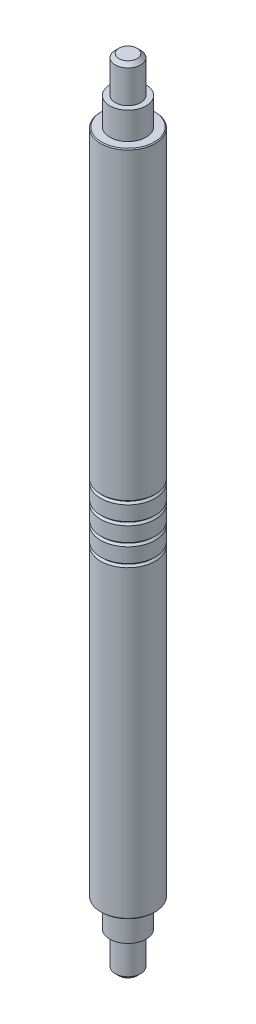
from build123d import *

# Parameters (mm, degrees)
SKETCH1_R           = 1.5
BOSS_EXTRUDE1_DEPTH = 43.75
SKETCH2_OUTSIDE_W   = 13.792
SKETCH2_OUTSIDE_H   = 13.792
SKETCH2_OUTSIDE_R   = 1
CUT_EXTRUDE1_DEPTH  = 3.5
SKETCH3_OUTSIDE_W   = 13.792
SKETCH3_OUTSIDE_H   = 13.792
SKETCH3_OUTSIDE_R   = 0.7
CUT_EXTRUDE2_DEPTH  = 2
SKETCH4_OUTSIDE_W   = 13.792
SKETCH4_OUTSIDE_H   = 13.792
SKETCH4_OUTSIDE_R   = 1
CUT_EXTRUDE5_DEPTH  = 3.5
SKETCH5_OUTSIDE_W   = 13.792
SKETCH5_OUTSIDE_H   = 13.792
SKETCH5_OUTSIDE_R   = 0.7
CUT_EXTRUDE6_DEPTH  = 2
LPATTERN1_COUNT     = 4
LPATTERN1_PITCH     = 1
CHAMFER3_SIZE       = 0.2
CHAMFER4_SIZE       = 0.05


with BuildPart() as part:
    # Sketch1 → Boss-Extrude1 (new body)
    with BuildSketch(Plane(origin=(0, 0, 0), x_dir=(1, 0, 0), z_dir=(0, 1, 0))):
        Circle(SKETCH1_R)
    extrude(amount=BOSS_EXTRUDE1_DEPTH)

    # Sketch2 outside → Cut-Extrude1 (cut)
    with BuildSketch(Plane(origin=(0, 43.75, 0), x_dir=(1, 0, 0), z_dir=(0, 1, 0))):
        Rectangle(SKETCH2_OUTSIDE_W, SKETCH2_OUTSIDE_H)
        Circle(SKETCH2_OUTSIDE_R, mode=Mode.SUBTRACT)
    extrude(amount=-CUT_EXTRUDE1_DEPTH, mode=Mode.SUBTRACT)

    # Sketch3 outside → Cut-Extrude2 (cut)
    with BuildSketch(Plane(origin=(0, 43.75, 0), x_dir=(1, 0, 0), z_dir=(0, 1, 0))):
        Rectangle(SKETCH3_OUTSIDE_W, SKETCH3_OUTSIDE_H)
        Circle(SKETCH3_OUTSIDE_R, mode=Mode.SUBTRACT)
    extrude(amount=-CUT_EXTRUDE2_DEPTH, mode=Mode.SUBTRACT)

    # Sketch4 outside → Cut-Extrude5 (cut)
    with BuildSketch(Plane.XZ):
        Rectangle(SKETCH4_OUTSIDE_W, SKETCH4_OUTSIDE_H)
        Circle(SKETCH4_OUTSIDE_R, mode=Mode.SUBTRACT)
    extrude(amount=-CUT_EXTRUDE5_DEPTH, mode=Mode.SUBTRACT)

    # Sketch5 outside → Cut-Extrude6 (cut)
    with BuildSketch(Plane.XZ):
        Rectangle(SKETCH5_OUTSIDE_W, SKETCH5_OUTSIDE_H)
        Circle(SKETCH5_OUTSIDE_R, mode=Mode.SUBTRACT)
    extrude(amount=-CUT_EXTRUDE6_DEPTH, mode=Mode.SUBTRACT)

    # Sketch6 → Cut-Revolve1 (revolve, cut)
    with BuildSketch(Plane.XY):
        Polygon((-1.5, 23.475), (-1.4, 23.375), (-1.5, 23.275), align=None)
    cut_revolve1 = revolve(axis=Axis((0, 43.75, 0), (0, -1, 0)), mode=Mode.SUBTRACT)

    # LPattern1: Cut-Revolve1 ×4
    with Locations(*[(0, -i * LPATTERN1_PITCH, 0) for i in range(1, LPATTERN1_COUNT)]):
        add(cut_revolve1, mode=Mode.SUBTRACT)

    # Chamfer3
    chamfer3_edges = [part.edges().sort_by_distance(p)[0] for p in [
        (-0.7, 43.75, 0),
        (-0.7, 0, 0),
    ]]
    chamfer(chamfer3_edges, length=CHAMFER3_SIZE)

    # Chamfer4
    chamfer4_edges = [part.edges().sort_by_distance(p)[0] for p in [
        (-1.5, 3.5, 0),
        (-1.5, 40.25, 0),
    ]]
    chamfer(chamfer4_edges, length=CHAMFER4_SIZE)


solid = part.part
